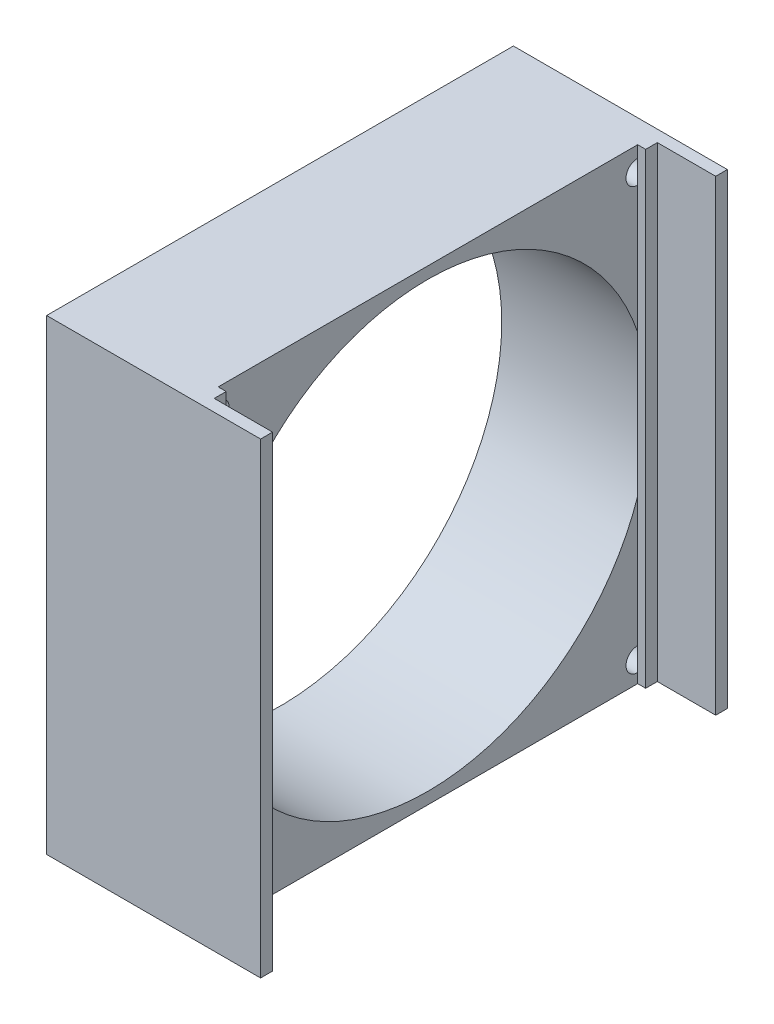
from build123d import *

# Parameters (mm, degrees)
SKETCH1_W           = 80
SKETCH1_H           = 80
BOSS_EXTRUDE1_DEPTH = 25.3
SKETCH2_R           = 38
CUT_EXTRUDE1_DEPTH  = 25.3
SKETCH4_R           = 2
CUT_EXTRUDE2_DEPTH  = 25.3
SKETCH9_R           = 2
CUT_EXTRUDE3_DEPTH  = 25.3
SKETCH10_W          = 4.103880803
SKETCH10_H          = 80
SKETCH10_W_2        = 4
BOSS_EXTRUDE2_DEPTH = 1.37
SKETCH11_W          = 2.051940402
SKETCH11_H          = 80
BOSS_EXTRUDE3_DEPTH = 10
SKETCH12_W          = 2
SKETCH12_H          = 80
BOSS_EXTRUDE4_DEPTH = 10


with BuildPart() as part:
    # Sketch1 → Boss-Extrude1 (new body)
    with BuildSketch(Plane(origin=(0, 0, 0), x_dir=(0, 0, -1), z_dir=(1, 0, 0))):
        with Locations((2.081688293, -16.943070175)):
            Rectangle(SKETCH1_W, SKETCH1_H)
    extrude(amount=BOSS_EXTRUDE1_DEPTH)

    # Sketch2 → Cut-Extrude1 (cut)
    with BuildSketch(Plane(origin=(25.3, 0, 0), x_dir=(0, 0, -1), z_dir=(1, 0, 0))):
        with Locations((2.081688293, -16.943070175)):
            Circle(SKETCH2_R)
    extrude(amount=-CUT_EXTRUDE1_DEPTH, mode=Mode.SUBTRACT)

    # Sketch4 → Cut-Extrude2 (cut)
    with BuildSketch(Plane.ZY):
        with Locations((-38.081688293, 19.056929825)):
            Circle(SKETCH4_R)
    extrude(amount=-CUT_EXTRUDE2_DEPTH, mode=Mode.SUBTRACT)

    # Sketch9 → Cut-Extrude3 (cut)
    with BuildSketch(Plane.ZY):
        with Locations((33.918311707, 19.056929825)):
            Circle(SKETCH9_R)
        with Locations((33.918311707, -52.943070175)):
            Circle(SKETCH9_R)
        with Locations((-38.081688293, -53.283129164)):
            Circle(SKETCH9_R)
    extrude(amount=-CUT_EXTRUDE3_DEPTH, mode=Mode.SUBTRACT)

    # Sketch10 → Boss-Extrude2 (add)
    with BuildSketch(Plane(origin=(25.3, 0, 0), x_dir=(0, 0, -1), z_dir=(1, 0, 0))):
        with Locations((-35.866371306, -16.943070175)):
            Rectangle(SKETCH10_W, SKETCH10_H)
        with Locations((40.081688293, -16.943070175)):
            Rectangle(SKETCH10_W_2, SKETCH10_H)
    extrude(amount=BOSS_EXTRUDE2_DEPTH)

    # Sketch11 → Boss-Extrude3 (add)
    with BuildSketch(Plane(origin=(26.67, 0, 0), x_dir=(0, 0, -1), z_dir=(1, 0, 0))):
        with Locations((-36.892341506, -16.943070175)):
            Rectangle(SKETCH11_W, SKETCH11_H)
    extrude(amount=BOSS_EXTRUDE3_DEPTH)

    # Sketch12 → Boss-Extrude4 (add)
    with BuildSketch(Plane(origin=(26.67, 0, 0), x_dir=(0, 0, -1), z_dir=(1, 0, 0))):
        with Locations((41.081688293, -16.943070175)):
            Rectangle(SKETCH12_W, SKETCH12_H)
    extrude(amount=BOSS_EXTRUDE4_DEPTH)


solid = part.part
